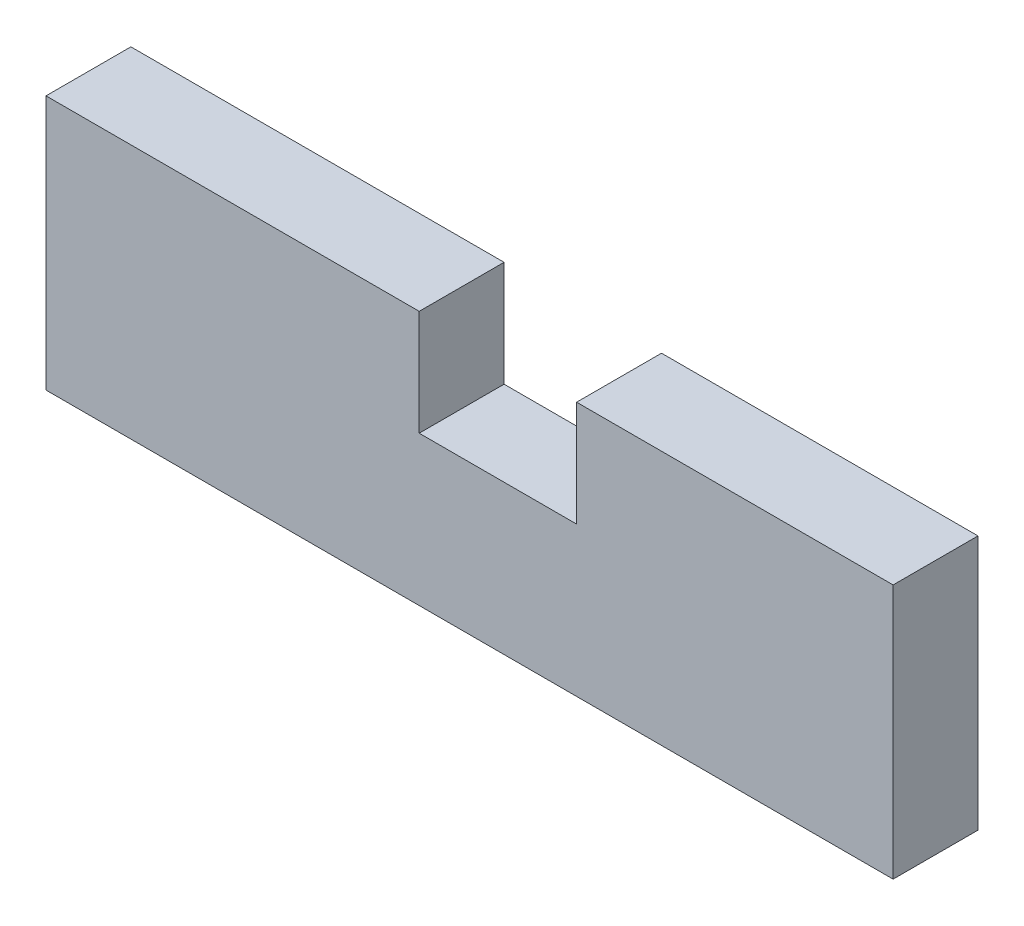
from build123d import *

# Parameters (mm, degrees)
EXTRUDE_1_DEPTH = 20


with BuildPart() as part:
    # Эскиз1 → Бобышка-Вытянуть1 (new body)
    with BuildSketch(Plane.XY):
        Polygon((0, 0), (199.570972782, 0), (199.570972782, 60.036230733), (125.007370997, 60.036230733), (125.007370997, 35.165288875), (87.922355901, 35.165288875), (87.922355901, 60.036230733), (0, 60.036230733), align=None)
    extrude(amount=EXTRUDE_1_DEPTH)


solid = part.part
